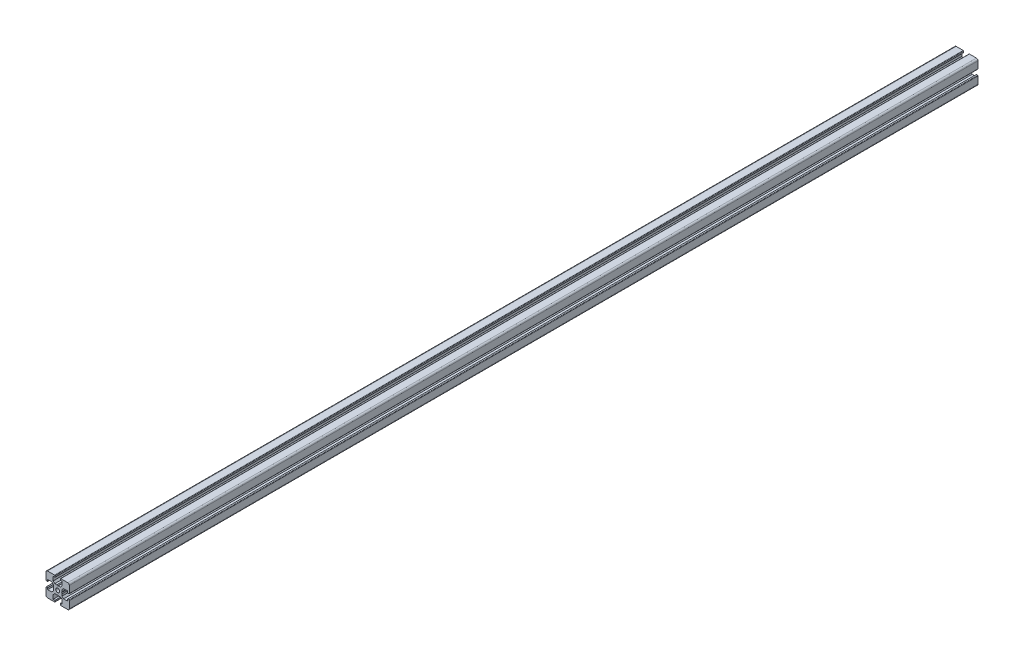
from build123d import *

# Parameters (mm, degrees)
SKETCH1_R           = 1.25
BOSS_EXTRUDE1_DEPTH = 584.45


with BuildPart() as part:
    # Sketch1 → Boss-Extrude1 (new body)
    with BuildSketch(Plane.XY.offset(114.5)):
        with BuildLine():
            Line((-7.5, 6.5), (-7.5, 2))
            ThreePointArc((-7.5, 2), (-7.412132034, 1.787867966), (-7.2, 1.7))
            Line((-7.2, 1.7), (-6.4, 1.7))
            Line((-6.4, 1.7), (-6.4, 2.85))
            Line((-6.4, 2.85), (-3.8, 2.85))
            Line((-3.8, 2.85), (-2.8, 1.85))
            Line((-2.8, 1.85), (-2.8, 0.519615242))
            Line((-2.8, 0.519615242), (-2.5, 0))
            Line((-2.5, 0), (-2.8, -0.519615242))
            Line((-2.8, -0.519615242), (-2.8, -1.85))
            Line((-2.8, -1.85), (-3.8, -2.85))
            Line((-3.8, -2.85), (-6.4, -2.85))
            Line((-6.4, -2.85), (-6.4, -1.7))
            Line((-6.4, -1.7), (-7.2, -1.7))
            ThreePointArc((-7.2, -1.7), (-7.412132034, -1.787867966), (-7.5, -2))
            Line((-7.5, -2), (-7.5, -6.5))
            ThreePointArc((-7.5, -6.5), (-7.207106781, -7.207106781), (-6.5, -7.5))
            Line((-6.5, -7.5), (-2, -7.5))
            ThreePointArc((-2, -7.5), (-1.787867966, -7.412132034), (-1.7, -7.2))
            Line((-1.7, -7.2), (-1.7, -6.4))
            Line((-1.7, -6.4), (-2.85, -6.4))
            Line((-2.85, -6.4), (-2.85, -3.8))
            Line((-2.85, -3.8), (-1.85, -2.8))
            Line((-1.85, -2.8), (-0.519615242, -2.8))
            Line((-0.519615242, -2.8), (0, -2.5))
            Line((0, -2.5), (0.519615242, -2.8))
            Line((0.519615242, -2.8), (1.85, -2.8))
            Line((1.85, -2.8), (2.85, -3.8))
            Line((2.85, -3.8), (2.85, -6.4))
            Line((2.85, -6.4), (1.7, -6.4))
            Line((1.7, -6.4), (1.7, -7.2))
            ThreePointArc((1.7, -7.2), (1.787867966, -7.412132034), (2, -7.5))
            Line((2, -7.5), (6.5, -7.5))
            ThreePointArc((6.5, -7.5), (7.207106781, -7.207106781), (7.5, -6.5))
            Line((7.5, -6.5), (7.5, -2))
            ThreePointArc((7.5, -2), (7.412132034, -1.787867966), (7.2, -1.7))
            Line((7.2, -1.7), (6.4, -1.7))
            Line((6.4, -1.7), (6.4, -2.85))
            Line((6.4, -2.85), (3.8, -2.85))
            Line((3.8, -2.85), (2.8, -1.85))
            Line((2.8, -1.85), (2.8, -0.519615242))
            Line((2.8, -0.519615242), (2.5, 0))
            Line((2.5, 0), (2.8, 0.519615242))
            Line((2.8, 0.519615242), (2.8, 1.85))
            Line((2.8, 1.85), (3.8, 2.85))
            Line((3.8, 2.85), (6.4, 2.85))
            Line((6.4, 2.85), (6.4, 1.7))
            Line((6.4, 1.7), (7.2, 1.7))
            ThreePointArc((7.2, 1.7), (7.412132034, 1.787867966), (7.5, 2))
            Line((7.5, 2), (7.5, 6.5))
            ThreePointArc((7.5, 6.5), (7.207106781, 7.207106781), (6.5, 7.5))
            Line((6.5, 7.5), (2, 7.5))
            ThreePointArc((2, 7.5), (1.787867966, 7.412132034), (1.7, 7.2))
            Line((1.7, 7.2), (1.7, 6.4))
            Line((1.7, 6.4), (2.85, 6.4))
            Line((2.85, 6.4), (2.85, 3.8))
            Line((2.85, 3.8), (1.85, 2.8))
            Line((1.85, 2.8), (0.519615242, 2.8))
            Line((0.519615242, 2.8), (0, 2.5))
            Line((0, 2.5), (-0.519615242, 2.8))
            Line((-0.519615242, 2.8), (-1.85, 2.8))
            Line((-1.85, 2.8), (-2.85, 3.8))
            Line((-2.85, 3.8), (-2.85, 6.4))
            Line((-2.85, 6.4), (-1.7, 6.4))
            Line((-1.7, 6.4), (-1.7, 7.2))
            ThreePointArc((-1.7, 7.2), (-1.787867966, 7.412132034), (-2, 7.5))
            Line((-2, 7.5), (-6.5, 7.5))
            ThreePointArc((-6.5, 7.5), (-7.207106781, 7.207106781), (-7.5, 6.5))
        make_face()
        Circle(SKETCH1_R, mode=Mode.SUBTRACT)
    extrude(amount=-BOSS_EXTRUDE1_DEPTH)


solid = part.part
